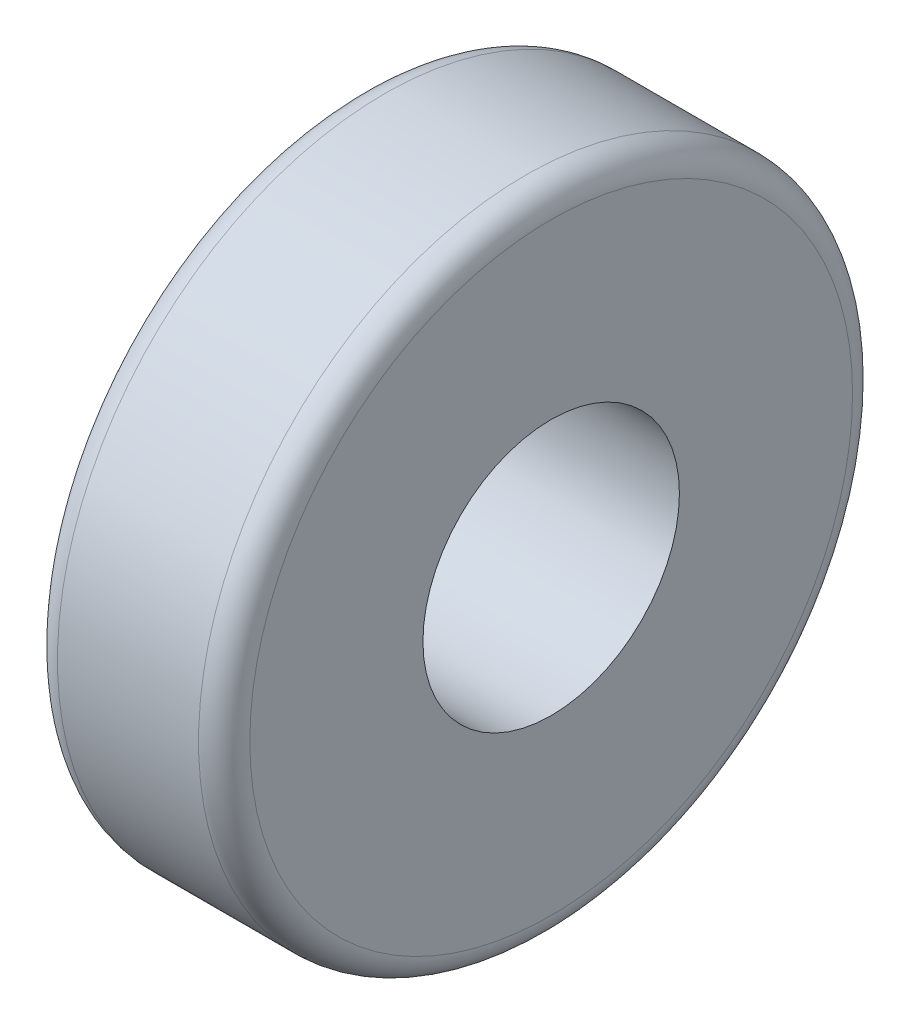
from build123d import *

# Parameters (mm, degrees)
SKETCH_1_R      = 2.55
SKETCH_1_R_2    = 1
EXTRUDE_1_DEPTH = 1.5
FILLET_1_R      = 0.2


with BuildPart() as part:
    # 草图1 → 凸台-拉伸1 (new body)
    with BuildSketch(Plane(origin=(0, 0, 0), x_dir=(0, 0, -1), z_dir=(1, 0, 0))):
        Circle(SKETCH_1_R)
        Circle(SKETCH_1_R_2, mode=Mode.SUBTRACT)
    extrude(amount=EXTRUDE_1_DEPTH)

    # 圆角1
    fillet_1_edges = [part.edges().sort_by_distance(p)[0] for p in [
        (0, 0, 2.55),
        (1.5, 0, 2.55),
    ]]
    fillet(fillet_1_edges, radius=FILLET_1_R)


solid = part.part
